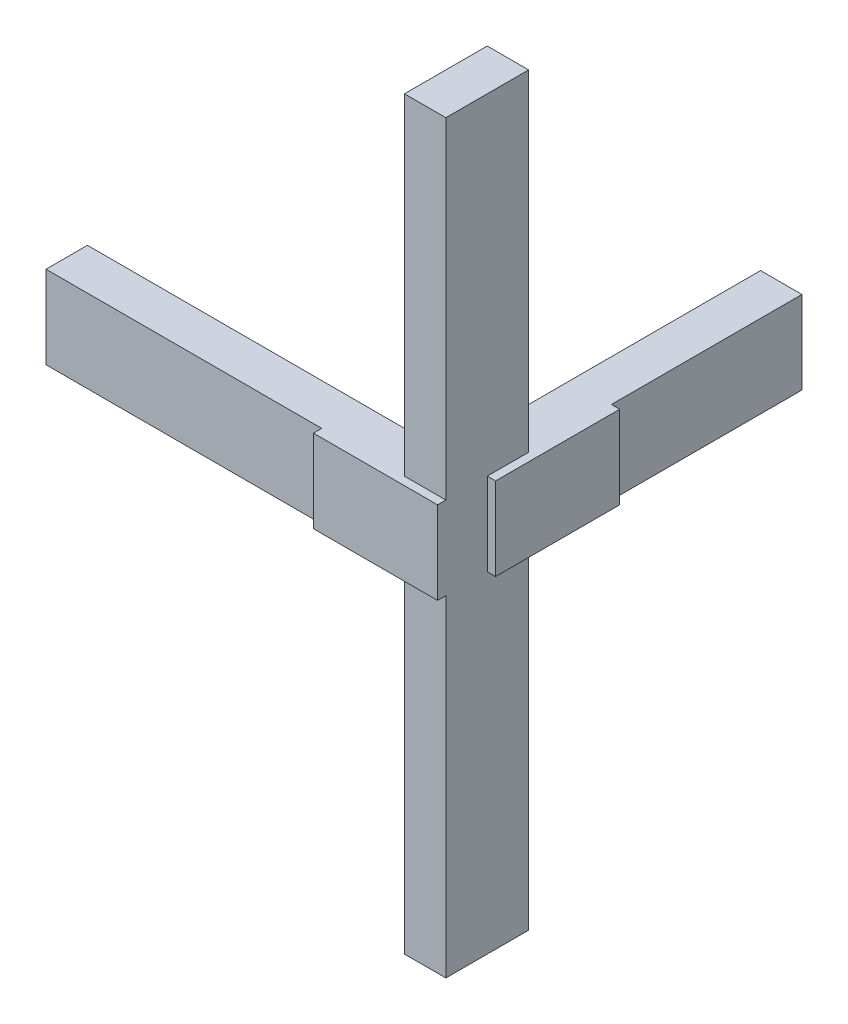
from build123d import *

# Parameters (mm, degrees)
BOSS_EXTRUDE1_DEPTH      = 40
BOSS_EXTRUDE2_DEPTH      = 200
BOSS_EXTRUDE2_DEPTH_BACK = 160


with BuildPart() as part:
    # Sketch1 → Boss-Extrude1 (new body)
    with BuildSketch(Plane(origin=(0, 0, 0), x_dir=(1, 0, 0), z_dir=(0, 1, 0))):
        Polygon((-173.191489362, -20), (-40, -20), (-40, -24), (20, -24), (20, 0), (24, 0), (24, 60), (20, 60), (20, 152.062590847), (0, 152.062590847), (0, 0), (-173.191489362, 0), align=None)
    extrude(amount=BOSS_EXTRUDE1_DEPTH)

    # Sketch1_3 → Boss-Extrude2 (add, two sides: drawn at the far end of the back side and taken through both)
    with BuildSketch(Plane(origin=(0, 0, 0), x_dir=(1, 0, 0), z_dir=(0, 1, 0)).offset(-BOSS_EXTRUDE2_DEPTH_BACK)):
        Polygon((0, 20), (0, 0), (0, -20), (20, -20), (20, 0), (20, 20), align=None)
    extrude(amount=BOSS_EXTRUDE2_DEPTH + BOSS_EXTRUDE2_DEPTH_BACK)


solid = part.part
